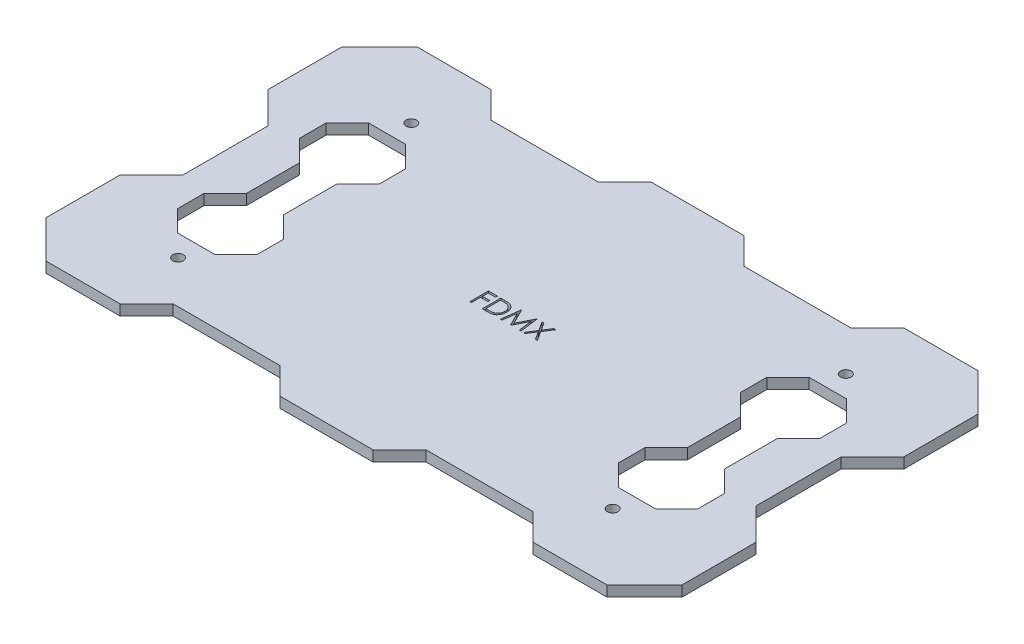
from build123d import *

# Parameters (mm, degrees)
SKETCH1_R                                  = 1
BOSS_EXTRUDE1_DEPTH                        = 2
MIRROR1_AT_THE_SECOND_PLANE_COPY_1_SKETC_R = 1
MIRROR1_AT_THE_SECOND_PLANE_COPY_1_DEPTH   = 2
CUT_EXTRUDE2_DEPTH                         = 2


with BuildPart() as part:
    # Sketch1 → Boss-Extrude1 (new body)
    with BuildSketch(Plane(origin=(0, 0, 0), x_dir=(1, 0, 0), z_dir=(0, 1, 0))):
        Polygon((0, 0), (-38.071067812, 0), (-38.071067812, 5), (-34.071067812, 9), (-34.071067812, 14), (-38.071067812, 18), (-45.071067812, 18), (-49.071067812, 14), (-49.071067812, 9), (-45.071067812, 5), (-45.071067812, 0), (-54.071067812, 0), (-54.071067812, 8), (-60, 13.928932188), (-60, 27.928932188), (-52.928932188, 35), (-38.928932188, 35), (-33.928932188, 30), (-13.776910945, 30), (-8.776910945, 35), (0, 35), align=None)
        with Locations((-41, 22)):
            Circle(SKETCH1_R, mode=Mode.SUBTRACT)
    boss_extrude1 = extrude(amount=BOSS_EXTRUDE1_DEPTH)



with BuildPart() as mirror1_1:
    # Mirror1: Boss-Extrude1 across plane
    add(boss_extrude1.mirror(Plane(origin=(0, 0, 0), x_dir=(0, 0, 1), z_dir=(1, 0, 0))))


with BuildPart() as part_1:
    add(part.part)

    add(mirror1_1.part)  # Mirror1 at the second plane merges Mirror1_1
    # Mirror1 at the second plane: Boss-Extrude1 across plane
    add(boss_extrude1.mirror(Plane.XY))

    # Mirror1 at the second plane copy 1 sketc → Mirror1 at the second plane copy 1 (add)
    with BuildSketch(Plane(origin=(0, 0, 0), x_dir=(-1, 0, 0), z_dir=(0, 1, 0))):
        Polygon((0, 0), (-38.071067812, 0), (-38.071067812, 5), (-34.071067812, 9), (-34.071067812, 14), (-38.071067812, 18), (-45.071067812, 18), (-49.071067812, 14), (-49.071067812, 9), (-45.071067812, 5), (-45.071067812, 0), (-54.071067812, 0), (-54.071067812, 8), (-60, 13.928932188), (-60, 27.928932188), (-52.928932188, 35), (-38.928932188, 35), (-33.928932188, 30), (-13.776910945, 30), (-8.776910945, 35), (0, 35), align=None)
        with Locations((-41, 22)):
            Circle(MIRROR1_AT_THE_SECOND_PLANE_COPY_1_SKETC_R, mode=Mode.SUBTRACT)
    extrude(amount=MIRROR1_AT_THE_SECOND_PLANE_COPY_1_DEPTH)

    # Sketch3 → Cut-Extrude2 (cut)
    with BuildSketch(Plane(origin=(0, 2, 0), x_dir=(1, 0, 0), z_dir=(0, 1, 0))):
        Polygon((-6.30208654, 1.856340481), (-4.596958334, 1.856340481), (-4.596958334, 1.497366122), (-5.987983975, 1.497366122), (-5.987983975, 0.420443045), (-4.596958334, 0.420443045), (-4.596958334, 0.061468686), (-5.987983975, 0.061468686), (-5.987983975, -1.643659519), (-6.30208654, -1.643659519), align=None)
        with BuildLine():
            Line((-3.968753206, -1.643659519), (-3.968753206, 1.856340481))
            Line((-3.968753206, 1.856340481), (-3.262022437, 1.856340481))
            add(Edge.make_bspline(
                [(-3.262022437, 1.856340481), (-3.200553449, 1.855897911), (-3.081795683, 1.855042868), (-2.910183236, 1.849621477), (-2.751399474, 1.840031011), (-2.605966614, 1.826061485), (-2.473485402, 1.808908451), (-2.354326794, 1.787408047), (-2.247874651, 1.762019877), (-2.182405211, 1.740374426), (-2.151445514, 1.730138558)],
                knots=[0, 0, 0, 0, 0.000184407, 0.000356273, 0.000515031, 0.000661537, 0.000794508, 0.000915664, 0.001024665, 0.001122454, 0.001122454, 0.001122454, 0.001122454], degree=3))
            add(Edge.make_bspline(
                [(-2.151445514, 1.730138558), (-2.110950775, 1.714707852), (-2.030879582, 1.684196358), (-1.91687246, 1.626640057), (-1.809547097, 1.561426955), (-1.708327952, 1.488471092), (-1.615527125, 1.405706744), (-1.527519229, 1.316649658), (-1.447904505, 1.218061318), (-1.374996209, 1.11198633), (-1.309260549, 0.999674278), (-1.252121392, 0.881339169), (-1.204667398, 0.757581961), (-1.165274172, 0.628746813), (-1.134227714, 0.494550435), (-1.113045782, 0.354836569), (-1.099074793, 0.21015738), (-1.097670741, 0.111982916), (-1.096958334, 0.062169808)],
                knots=[0, 0, 0, 0, 0.000129935, 0.000256923, 0.000382457, 0.000506429, 0.000630624, 0.000755071, 0.000881654, 0.001010204, 0.001140916, 0.00127168, 0.001403968, 0.001538146, 0.001675568, 0.001816774, 0.001961818, 0.002111216, 0.002111216, 0.002111216, 0.002111216], degree=3))
            add(Edge.make_bspline(
                [(-1.096958334, 0.062169808), (-1.097587302, 0.018908569), (-1.098826748, -0.06634222), (-1.109956064, -0.191983115), (-1.126132384, -0.313896687), (-1.151176582, -0.431502387), (-1.181579095, -0.545830604), (-1.220543246, -0.655662849), (-1.265178743, -0.762006658), (-1.317228621, -0.863424134), (-1.374370006, -0.959507506), (-1.435691749, -1.050083035), (-1.501128445, -1.133858256), (-1.571304078, -1.211086868), (-1.645311794, -1.281652447), (-1.723636125, -1.346144462), (-1.806479176, -1.403301017), (-1.893469898, -1.455368125), (-1.987146027, -1.500788481), (-2.089281894, -1.53921849), (-2.200313072, -1.571065106), (-2.319967029, -1.597636002), (-2.448450506, -1.618713304), (-2.585889472, -1.632839697), (-2.732072762, -1.642392629), (-2.832452027, -1.643229023), (-2.88411779, -1.643659519)],
                knots=[0, 0, 0, 0, 0.000129755, 0.000255696, 0.000378151, 0.000498469, 0.000616165, 0.000732801, 0.000847787, 0.000961923, 0.00107447, 0.001182981, 0.001289856, 0.001393094, 0.001495748, 0.001596383, 0.00169713, 0.001797413, 0.001900265, 0.002008995, 0.002124372, 0.002246504, 0.002376522, 0.002514729, 0.002660846, 0.00281582, 0.00281582, 0.00281582, 0.00281582], degree=3))
            Line((-2.88411779, -1.643659519), (-3.968753206, -1.643659519))
        make_face()
        with BuildLine():
            Line((-3.654650642, -1.28468516), (-3.252907854, -1.28468516))
            add(Edge.make_bspline(
                [(-3.252907854, -1.28468516), (-3.195179483, -1.284437064), (-3.084146684, -1.283959884), (-2.924488687, -1.27977268), (-2.778609291, -1.272930743), (-2.646487781, -1.263355665), (-2.528198757, -1.25068705), (-2.423495007, -1.236562147), (-2.332719749, -1.218964696), (-2.277790312, -1.203013737), (-2.252407052, -1.195642692)],
                knots=[0, 0, 0, 0, 0.000173183, 0.000333094, 0.000479096, 0.000611272, 0.000730431, 0.000835931, 0.000928194, 0.001007458, 0.001007458, 0.001007458, 0.001007458], degree=3))
            add(Edge.make_bspline(
                [(-2.252407052, -1.195642692), (-2.22045869, -1.184391134), (-2.157325052, -1.162156761), (-2.066443967, -1.121599099), (-1.981686962, -1.07355703), (-1.901576937, -1.020154756), (-1.827250282, -0.959508754), (-1.757826165, -0.892937765), (-1.693444364, -0.82010299), (-1.634770056, -0.741094828), (-1.582261752, -0.656405033), (-1.536790522, -0.566866199), (-1.496938991, -0.473459389), (-1.465660398, -0.37475023), (-1.441144814, -0.271621172), (-1.423780126, -0.164064958), (-1.412965402, -0.052101677), (-1.411703954, 0.024050448), (-1.411060898, 0.06287093)],
                knots=[0, 0, 0, 0, 0.000101593, 0.000200759, 0.000298073, 0.000393552, 0.000489254, 0.000585454, 0.000681817, 0.000780535, 0.000880346, 0.000980374, 0.001081551, 0.001184655, 0.001290601, 0.001399295, 0.001511268, 0.001627707, 0.001627707, 0.001627707, 0.001627707], degree=3))
            add(Edge.make_bspline(
                [(-1.411060898, 0.06287093), (-1.411574186, 0.10380441), (-1.412582543, 0.184218594), (-1.425256854, 0.30220929), (-1.443778409, 0.41568994), (-1.470562095, 0.524668136), (-1.504692974, 0.629356488), (-1.547287616, 0.729175998), (-1.595954235, 0.825180867), (-1.653857572, 0.915155232), (-1.717273165, 1.000248342), (-1.787651045, 1.078203257), (-1.863873083, 1.149197557), (-1.945107933, 1.21433687), (-2.033645032, 1.271000546), (-2.127398723, 1.321687227), (-2.227744394, 1.364703118), (-2.29755709, 1.387581981), (-2.333036059, 1.399209071)],
                knots=[0, 0, 0, 0, 0.000122746, 0.000241136, 0.000355593, 0.000467485, 0.000577457, 0.000685538, 0.00079278, 0.000899951, 0.001006101, 0.00111085, 0.001214524, 0.001318328, 0.001422759, 0.001529413, 0.00163777, 0.001749741, 0.001749741, 0.001749741, 0.001749741], degree=3))
            add(Edge.make_bspline(
                [(-2.333036059, 1.399209071), (-2.362387205, 1.407325499), (-2.424795795, 1.424583251), (-2.526635259, 1.443408624), (-2.641250409, 1.460013123), (-2.76915011, 1.474071162), (-2.910188569, 1.484158483), (-3.064474257, 1.491729798), (-3.232073862, 1.49683643), (-3.348256395, 1.497185138), (-3.408556892, 1.497366122)],
                knots=[0, 0, 0, 0, 9.1321e-05, 0.000194173, 0.000310382, 0.000438754, 0.000580072, 0.000734511, 0.000902151, 0.001083046, 0.001083046, 0.001083046, 0.001083046], degree=3))
            Line((-3.408556892, 1.497366122), (-3.654650642, 1.497366122))
            Line((-3.654650642, 1.497366122), (-3.654650642, -1.28468516))
        make_face(mode=Mode.SUBTRACT)
        Polygon((-0.558496796, -1.643659519), (-0.096457533, 1.856340481), (-0.051585738, 1.856340481), (1.393426281, -1.015454391), (2.834932691, 1.856340481), (2.880505608, 1.856340481), (3.345349358, -1.643659519), (3.02984455, -1.643659519), (2.694708332, 0.874769968), (1.431286858, -1.643659519), (1.360473557, -1.643659519), (0.09214423, 0.880378942), (-0.242290866, -1.643659519), align=None)
        Polygon((3.816503204, 1.856340481), (4.178983172, 1.856340481), (5.095349358, 0.424649776), (6.011715544, 1.856340481), (6.374195512, 1.856340481), (5.276939903, 0.141396571), (6.419067307, -1.643659519), (6.056587339, -1.643659519), (5.095349358, -0.141856634), (4.134111377, -1.643659519), (3.771631409, -1.643659519), (4.914459935, 0.141396571), align=None)
    extrude(amount=-CUT_EXTRUDE2_DEPTH, mode=Mode.SUBTRACT)


solid = part_1.part
